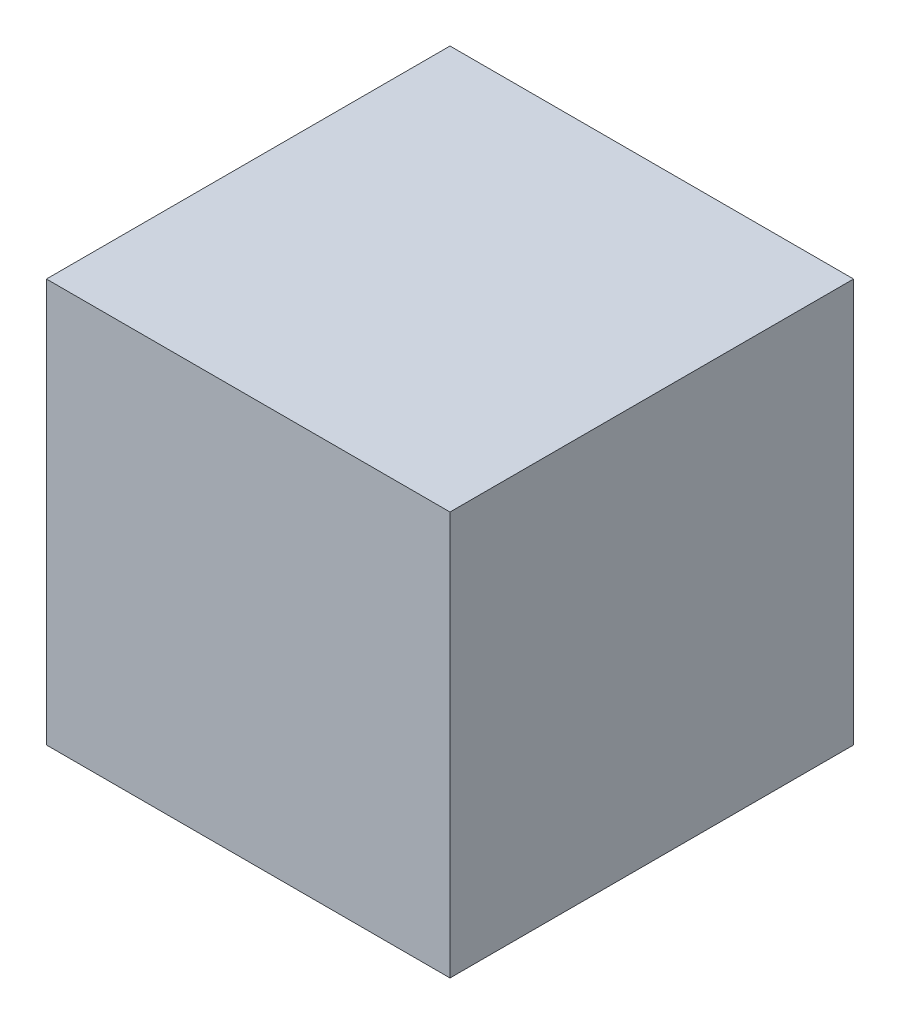
from build123d import *

# Parameters (mm, degrees)
ESQUISSE1_W      = 22
ESQUISSE1_H      = 22
EXTRUSION1_DEPTH = 22


with BuildPart() as part:
    # Esquisse1 → Extrusion1 (new body)
    with BuildSketch(Plane(origin=(0, 0, 0), x_dir=(1, 0, 0), z_dir=(0, 1, 0))):
        with Locations((11, 11)):
            Rectangle(ESQUISSE1_W, ESQUISSE1_H)
    extrude(amount=EXTRUSION1_DEPTH)


solid = part.part
